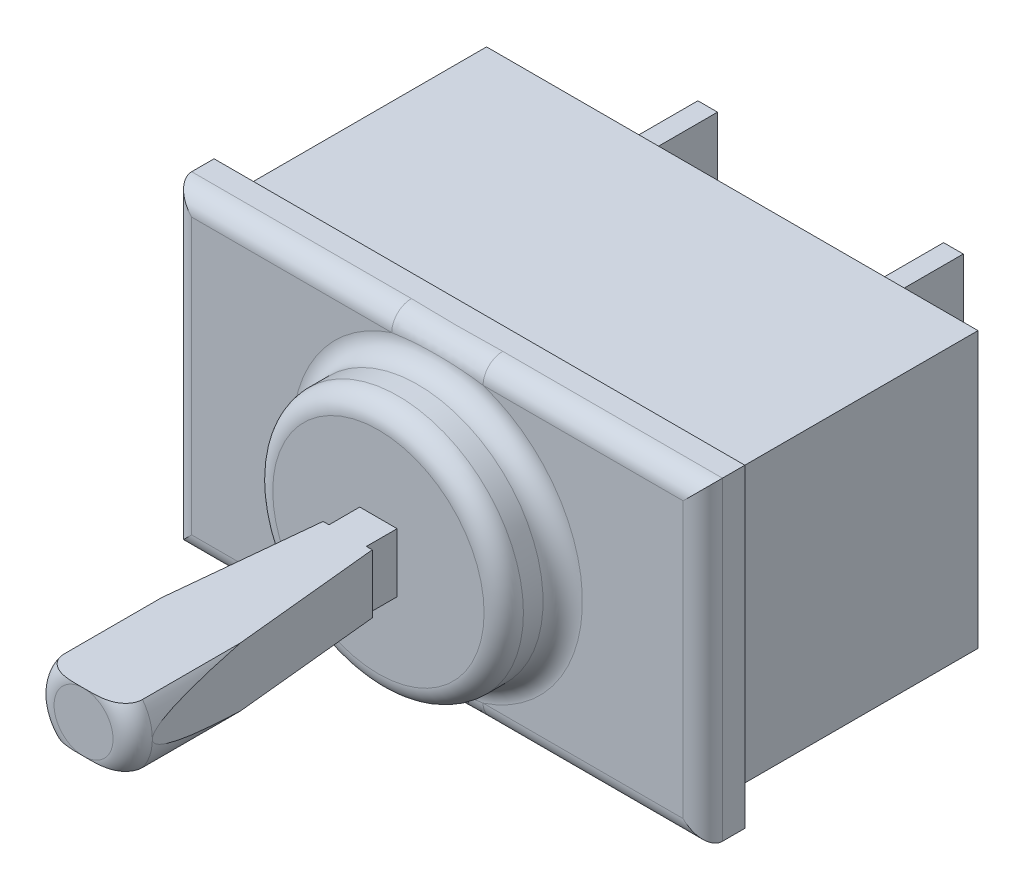
from build123d import *

# Parameters (mm, degrees)
ESQUISSE1_W             = 27
ESQUISSE1_H             = 15
BOSS_EXTRU_1_DEPTH      = 16
ESQUISSE2_W             = 1
ESQUISSE2_H             = 12.860678648
ENL_V_MAT_EXTRU_1_DEPTH = 16
ESQUISSE3_W             = 12.860678648
ESQUISSE3_H             = 1
ENL_V_MAT_EXTRU_2_DEPTH = 26
ESQUISSE4_R             = 6.375627484
BOSS_EXTRU_2_DEPTH      = 3
ESQUISSE5_R             = 2.5
BOSS_EXTRU_3_DEPTH      = 15
CONG_4_R                = 1
ESQUISSE6_W             = 7.518022456
ESQUISSE6_H             = 15.453712828
ENL_V_MAT_EXTRU_4_DEPTH = 6.5
ESQUISSE7_W             = 7.269073366
ESQUISSE7_H             = 15.09730622
ENL_V_MAT_EXTRU_5_DEPTH = 6.5
ENL_V_MAT_EXTRU_6_DEPTH = 6.5
CONG_5_R                = 1
CONG_6_R                = 1
ESQUISSE9_W             = 1
ESQUISSE9_H             = 10
BOSS_EXTRU_4_DEPTH      = 5
ESQUISSE10_R            = 1.625
ENL_V_MAT_EXTRU_7_DEPTH = 18


with BuildPart() as part:
    # Esquisse1 → Boss.-Extru.1 (new body)
    with BuildSketch(Plane(origin=(0, 0, 0), x_dir=(1, 0, 0), z_dir=(0, 1, 0))):
        Rectangle(ESQUISSE1_W, ESQUISSE1_H)
    extrude(amount=BOSS_EXTRU_1_DEPTH)

    # Esquisse2 → Enlèv. mat.-Extru.1 (cut)
    with BuildSketch(Plane.XZ):
        with Locations((-13, -1.069660676)):
            Rectangle(ESQUISSE2_W, ESQUISSE2_H)
        with Locations((13, -1.069660676)):
            Rectangle(ESQUISSE2_W, ESQUISSE2_H)
    extrude(amount=-ENL_V_MAT_EXTRU_1_DEPTH, mode=Mode.SUBTRACT)

    # Esquisse3 → Enlèv. mat.-Extru.2 (cut)
    with BuildSketch(Plane(origin=(12.5, 0, 0), x_dir=(0, 0, -1), z_dir=(1, 0, 0))):
        with Locations((1.069660676, 0.5)):
            Rectangle(ESQUISSE3_W, ESQUISSE3_H)
        with Locations((1.069660676, 15.5)):
            Rectangle(ESQUISSE3_W, ESQUISSE3_H)
    extrude(amount=-ENL_V_MAT_EXTRU_2_DEPTH, mode=Mode.SUBTRACT)

    # Esquisse4 → Boss.-Extru.2 (add)
    with BuildSketch(Plane.XY.offset(7.5)):
        with Locations((0, 8)):
            Circle(ESQUISSE4_R)
    extrude(amount=BOSS_EXTRU_2_DEPTH)

    # Esquisse5 → Boss.-Extru.3 (add)
    with BuildSketch(Plane.XY.offset(10.5)):
        with Locations((0, 8)):
            Circle(ESQUISSE5_R)
    extrude(amount=BOSS_EXTRU_3_DEPTH)

    # Congé4
    cong_4_edges = [part.edges().sort_by_distance(p)[0] for p in [
        (-2.5, 8, 25.5),
    ]]
    fillet(cong_4_edges, radius=CONG_4_R)

    # Esquisse6 → Enlèv. mat.-Extru.4 (cut)
    with BuildSketch(Plane(origin=(0, 16, 0), x_dir=(1, 0, 0), z_dir=(0, 1, 0))):
        with Locations((0, -18.226856414)):
            Rectangle(ESQUISSE6_W, ESQUISSE6_H)
    extrude(amount=-ENL_V_MAT_EXTRU_4_DEPTH, mode=Mode.SUBTRACT)

    # Esquisse7 → Enlèv. mat.-Extru.5 (cut)
    with BuildSketch(Plane.XZ):
        with Locations((0, 18.04865311)):
            Rectangle(ESQUISSE7_W, ESQUISSE7_H)
    extrude(amount=-ENL_V_MAT_EXTRU_5_DEPTH, mode=Mode.SUBTRACT)

    # Esquisse8 → Enlèv. mat.-Extru.6 (cut)
    with BuildSketch(Plane(origin=(0, 9.5, 0), x_dir=(1, 0, 0), z_dir=(0, 1, 0))):
        Polygon((2, -19.525589234), (2, -10.5), (0.951197678, -10.5), (0.951197678, -12.063973085), (1.25, -12.063973085), align=None)
        Polygon((2.5, -24.5), (2.5, -10.5), (2, -10.5), (2, -19.525589234), align=None)
        Polygon((-2.5, -10.5), (-0.951197678, -10.5), (-0.951197678, -12.063973085), (-1.25, -12.063973085), (-2.5, -24.5), align=None)
    extrude(amount=-ENL_V_MAT_EXTRU_6_DEPTH, mode=Mode.SUBTRACT)

    # Congé5
    cong_5_edges = [part.edges().sort_by_distance(p)[0] for p in [
        (-6.375627484, 8, 7.5),
        (-6.375627484, 8, 10.5),
    ]]
    fillet(cong_5_edges, radius=CONG_5_R)

    # Congé6
    cong_6_edges = [part.edges().sort_by_distance(p)[0] for p in [
        (0, 16, 7.5),
        (0, 0, 7.5),
        (13.5, 8, 7.5),
        (-13.5, 8, 7.5),
    ]]
    fillet(cong_6_edges, radius=CONG_6_R)

    # Esquisse9 → Boss.-Extru.4 (add)
    with BuildSketch(Plane(origin=(0, 0, -7.5), x_dir=(-1, 0, 0), z_dir=(0, 0, -1))):
        with Locations((6.25, 8)):
            Rectangle(ESQUISSE9_W, ESQUISSE9_H)
        with Locations((-6.25, 8)):
            Rectangle(ESQUISSE9_W, ESQUISSE9_H)
    extrude(amount=BOSS_EXTRU_4_DEPTH)

    # Esquisse10 → Enlèv. mat.-Extru.7 (cut)
    with BuildSketch(Plane.ZY.offset(6.75)):
        with Locations((-10, 8)):
            Circle(ESQUISSE10_R)
    extrude(amount=-ENL_V_MAT_EXTRU_7_DEPTH, mode=Mode.SUBTRACT)


solid = part.part
